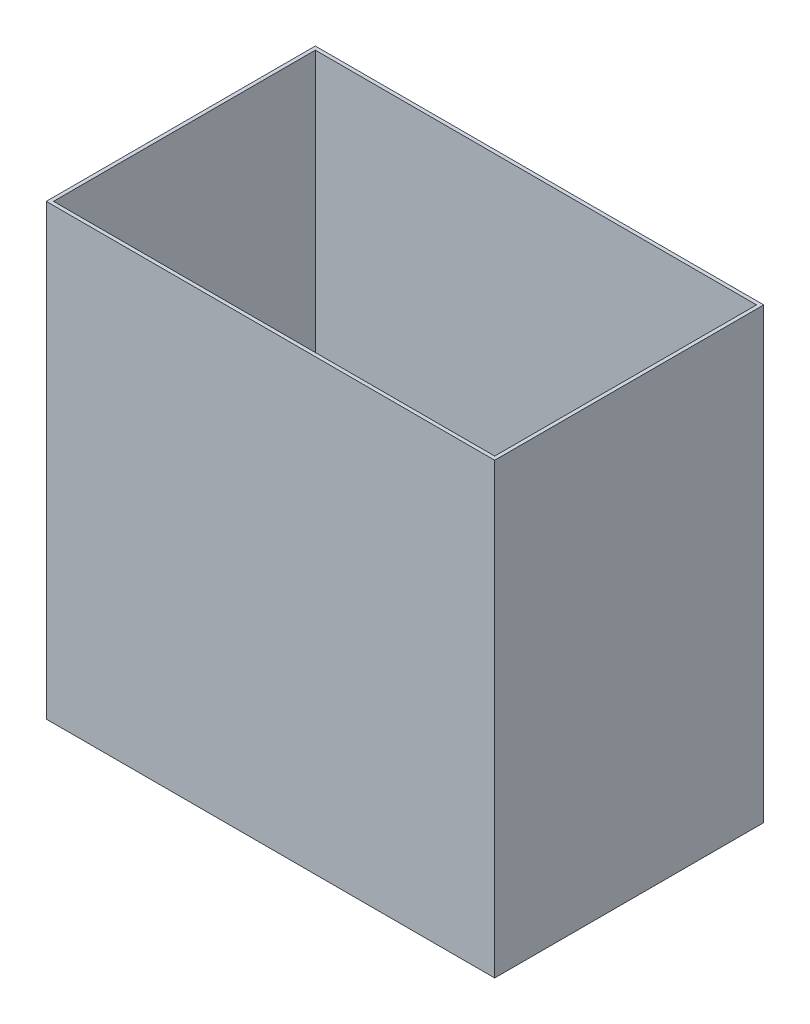
from build123d import *

# Parameters (mm, degrees)
SKETCH_1_W          = 250
SKETCH_1_H          = 250
EXTRUDE_2_DEPTH     = 150
CUT_EXTRUDE_START   = 250
SKETCH_3_W          = 246
SKETCH_3_H          = 146
CUT_EXTRUDE_1_DEPTH = 248


with BuildPart() as part:
    # 草图1 → 凸台-拉伸2 (new body)
    with BuildSketch(Plane.XY):
        with Locations((125, 125)):
            Rectangle(SKETCH_1_W, SKETCH_1_H)
    extrude(amount=EXTRUDE_2_DEPTH)

    # 草图3 → 切除-拉伸1 (cut)
    with BuildSketch(Plane(origin=(0, 0, 0), x_dir=(1, 0, 0), z_dir=(0, 1, 0)).offset(CUT_EXTRUDE_START)):
        with Locations((125, -75)):
            Rectangle(SKETCH_3_W, SKETCH_3_H)
    extrude(amount=-CUT_EXTRUDE_1_DEPTH, mode=Mode.SUBTRACT)


solid = part.part
